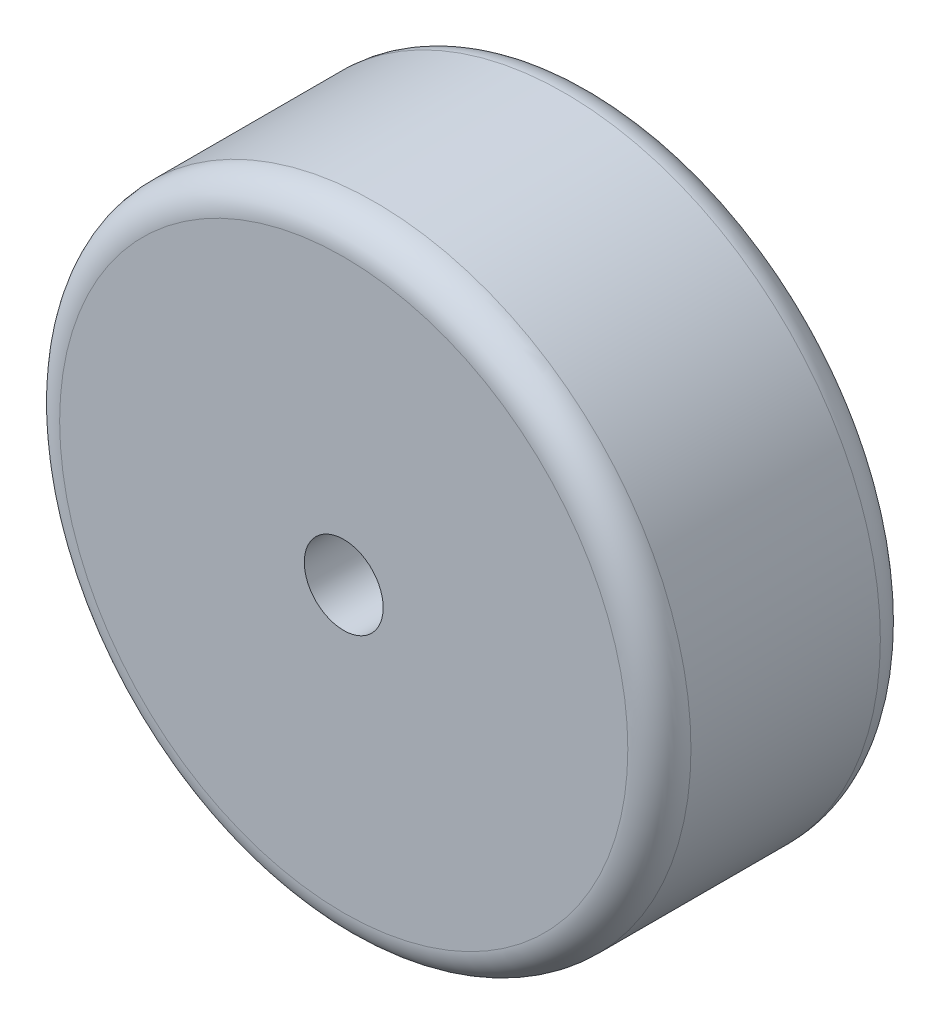
from build123d import *

# Parameters (mm, degrees)
SKETCH1_R           = 25.4
SKETCH1_R_2         = 3.175
BOSS_EXTRUDE1_DEPTH = 20.32
FILLET1_R           = 2.54


with BuildPart() as part:
    # Sketch1 → Boss-Extrude1 (new body)
    with BuildSketch(Plane.XY):
        Circle(SKETCH1_R)
        Circle(SKETCH1_R_2, mode=Mode.SUBTRACT)
    extrude(amount=BOSS_EXTRUDE1_DEPTH)

    # Fillet1
    fillet1_edges = [part.edges().sort_by_distance(p)[0] for p in [
        (-25.4, 0, 0),
        (-25.4, 0, 20.32),
    ]]
    fillet(fillet1_edges, radius=FILLET1_R)


solid = part.part
